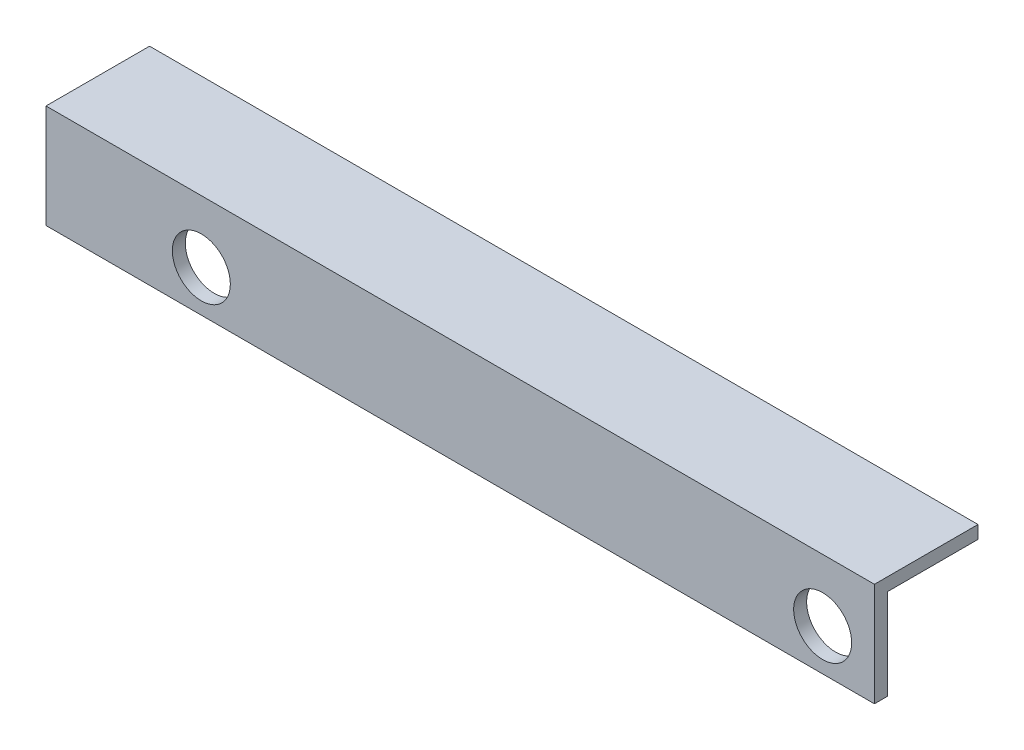
from build123d import *

# Parameters (mm, degrees)
BOSS_EXTRUDE1_DEPTH      = 44.45
BOSS_EXTRUDE1_DEPTH_BACK = 57.15
SKETCH3_R                = 3.556
CUT_EXTRUDE1_DEPTH       = 13.7


with BuildPart() as part:
    # Sketch1 → Boss-Extrude1 (new body, two sides)
    with BuildSketch(Plane(origin=(0, 0, 0), x_dir=(0, 0, -1), z_dir=(1, 0, 0))) as boss_extrude1_sk:
        Polygon((0, 0), (0, 12.7), (12.7, 12.7), (12.7, 11.1125), (1.5875, 11.1125), (1.5875, 0), align=None)
    extrude(amount=BOSS_EXTRUDE1_DEPTH)
    extrude(boss_extrude1_sk.sketch, amount=-BOSS_EXTRUDE1_DEPTH_BACK)

    # Sketch3 → Cut-Extrude1 (cut, through all)
    with BuildSketch(Plane.XY):
        with Locations((-38.1, 5.08)):
            Circle(SKETCH3_R)
        with Locations((38.1, 5.08)):
            Circle(SKETCH3_R)
    extrude(amount=-CUT_EXTRUDE1_DEPTH, mode=Mode.SUBTRACT)


solid = part.part
